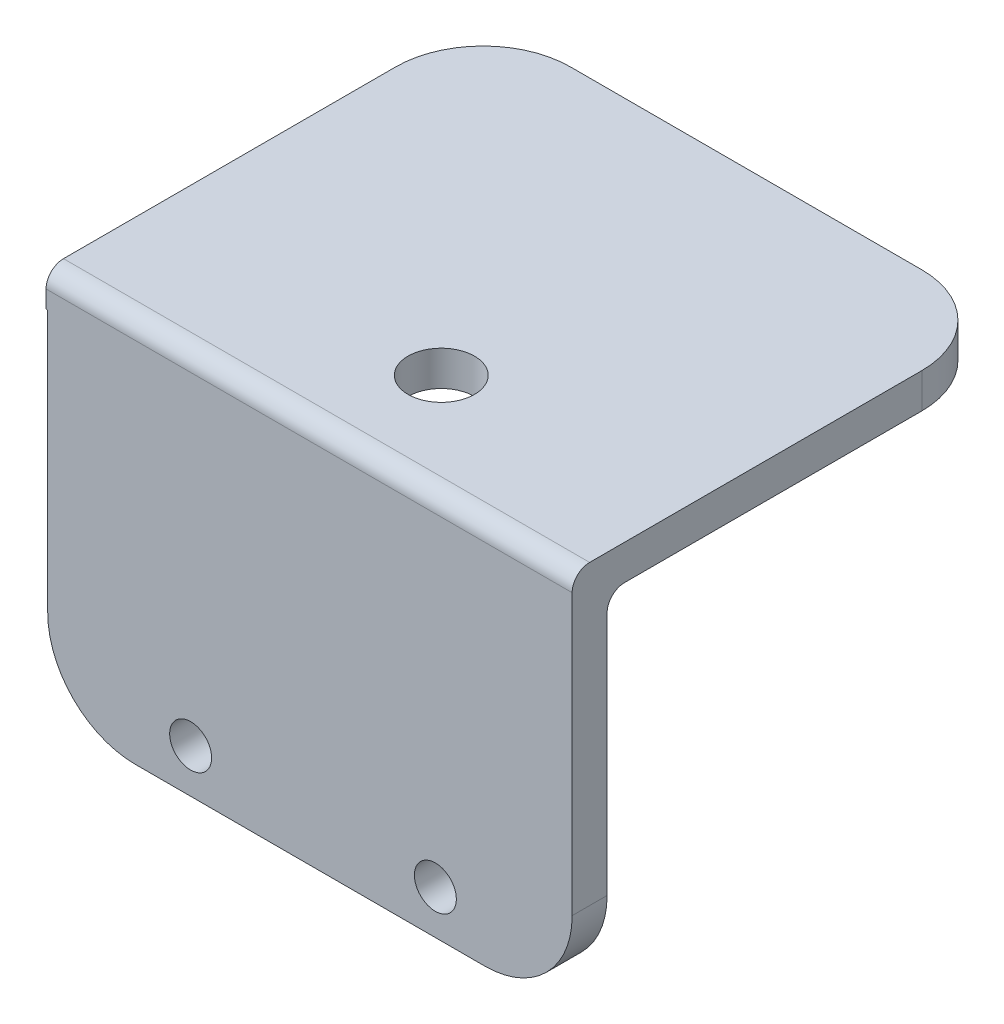
from build123d import *

# Parameters (mm, degrees)
SKETCH2_W           = 30
SKETCH2_H           = 22
BOSS_EXTRUDE1_DEPTH = 2
SKETCH3_W           = 30.097036207
SKETCH3_H           = 25
BOSS_EXTRUDE2_DEPTH = 2
SKETCH4_R           = 1.2
CUT_EXTRUDE1_DEPTH  = 2
FILLET1_R           = 1
FILLET2_R           = 1
FILLET3_R           = 5
FILLET4_R           = 5
SKETCH5_R           = 1.9
CUT_EXTRUDE2_DEPTH  = 2


with BuildPart() as part:
    # Sketch2 → Boss-Extrude1 (new body)
    with BuildSketch(Plane.XY):
        with Locations((-12.375323898, 10.6)):
            Rectangle(SKETCH2_W, SKETCH2_H)
    extrude(amount=BOSS_EXTRUDE1_DEPTH)

    # Sketch3 → Boss-Extrude2 (add)
    with BuildSketch(Plane(origin=(0, 21.6, 0), x_dir=(1, 0, 0), z_dir=(0, 1, 0))):
        with Locations((-12.423842002, 10.5)):
            Rectangle(SKETCH3_W, SKETCH3_H)
    extrude(amount=-BOSS_EXTRUDE2_DEPTH)

    # Sketch4 → Cut-Extrude1 (cut)
    with BuildSketch(Plane.XY.offset(2)):
        with Locations((-5.2, 2.1)):
            Circle(SKETCH4_R)
        with Locations((-19.2, 2.1)):
            Circle(SKETCH4_R)
    extrude(amount=-CUT_EXTRUDE1_DEPTH, mode=Mode.SUBTRACT)

    # Fillet1
    fillet1_edges = [part.edges().sort_by_distance(p)[0] for p in [
        (-12.375323898, 19.6, 0),
    ]]
    fillet(fillet1_edges, radius=FILLET1_R)

    # Fillet2
    fillet2_edges = [part.edges().sort_by_distance(p)[0] for p in [
        (-12.423842002, 21.6, 2),
    ]]
    fillet(fillet2_edges, radius=FILLET2_R)

    # Fillet3
    fillet3_edges = [part.edges().sort_by_distance(p)[0] for p in [
        (2.624676102, -0.4, 1),
        (-27.375323898, -0.4, 1),
    ]]
    fillet(fillet3_edges, radius=FILLET3_R)

    # Fillet4
    fillet4_edges = [part.edges().sort_by_distance(p)[0] for p in [
        (2.624676102, 20.6, -23),
        (-27.472360105, 20.6, -23),
    ]]
    fillet(fillet4_edges, radius=FILLET4_R)

    # Sketch5 → Cut-Extrude2 (cut)
    with BuildSketch(Plane(origin=(0, 21.6, 0), x_dir=(1, 0, 0), z_dir=(0, 1, 0))):
        with Locations((-10.890638189, 4.027670227)):
            Circle(SKETCH5_R)
    extrude(amount=-CUT_EXTRUDE2_DEPTH, mode=Mode.SUBTRACT)


solid = part.part
